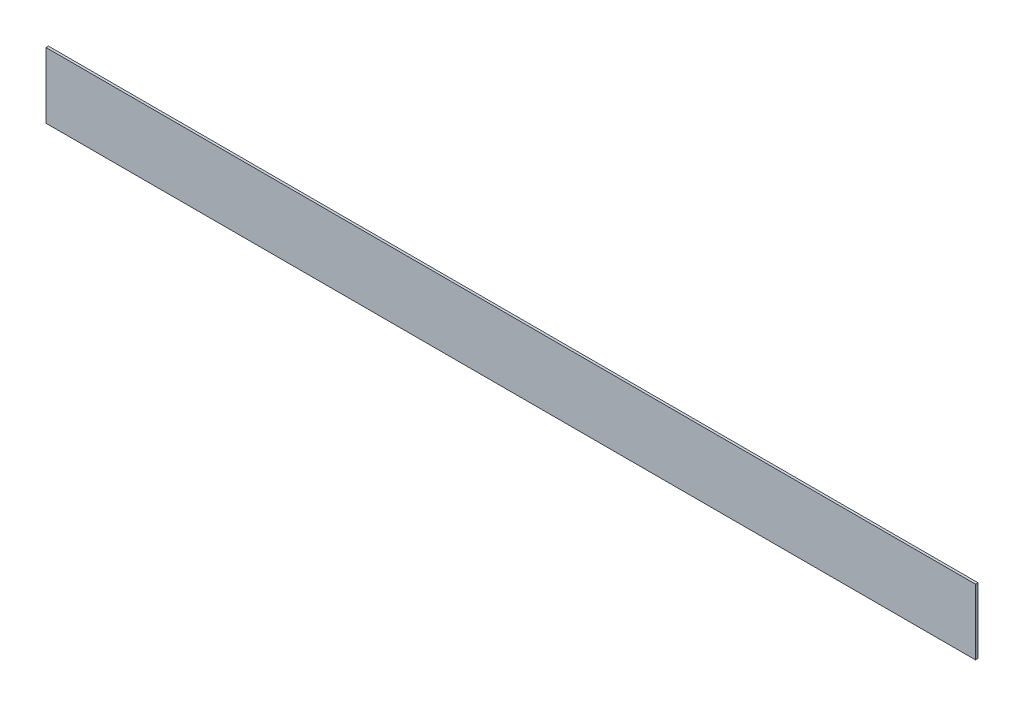
from build123d import *

# Parameters (mm, degrees)
SKETCH1_W           = 1504
SKETCH1_H           = 106.14
BOSS_EXTRUDE1_DEPTH = 4


with BuildPart() as part:
    # Sketch1 → Boss-Extrude1 (new body)
    with BuildSketch(Plane.XY):
        with Locations((114.001649485, 679.548556701)):
            Rectangle(SKETCH1_W, SKETCH1_H)
    extrude(amount=BOSS_EXTRUDE1_DEPTH)


solid = part.part
